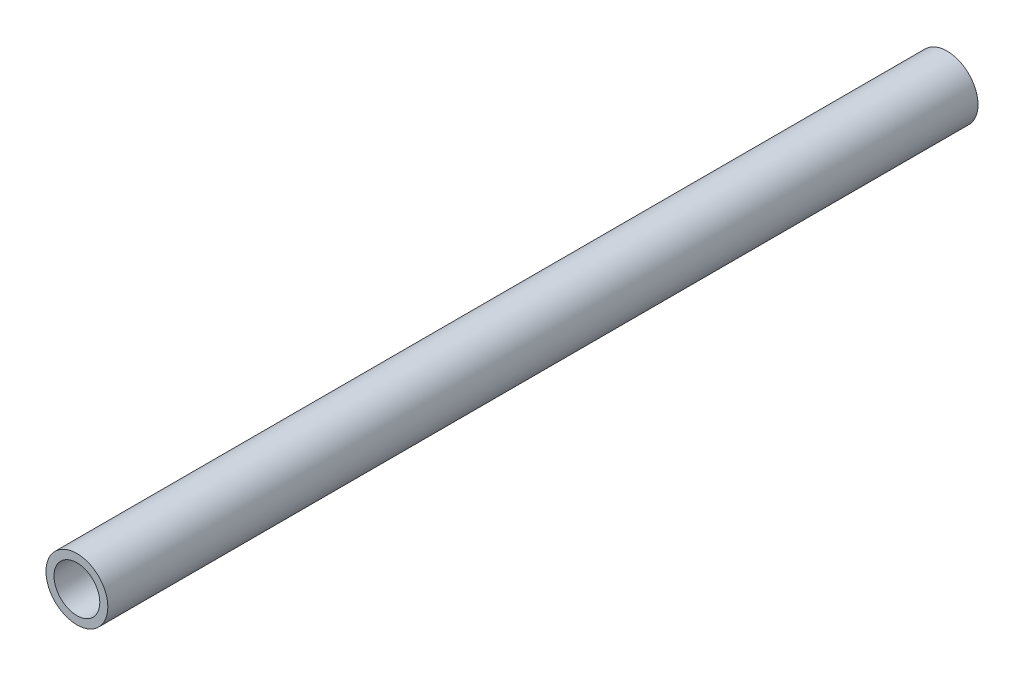
from build123d import *

# Parameters (mm, degrees)
SKETCH1_R           = 10.668
SKETCH1_R_2         = 7.8994
EXTRUDE_THIN1_DEPTH = 150


with BuildPart() as part:
    # Sketch1 → Extrude-Thin1 (new body, symmetric)
    with BuildSketch(Plane.XY):
        Circle(SKETCH1_R)
        Circle(SKETCH1_R_2, mode=Mode.SUBTRACT)
    extrude(amount=EXTRUDE_THIN1_DEPTH, both=True)


solid = part.part
